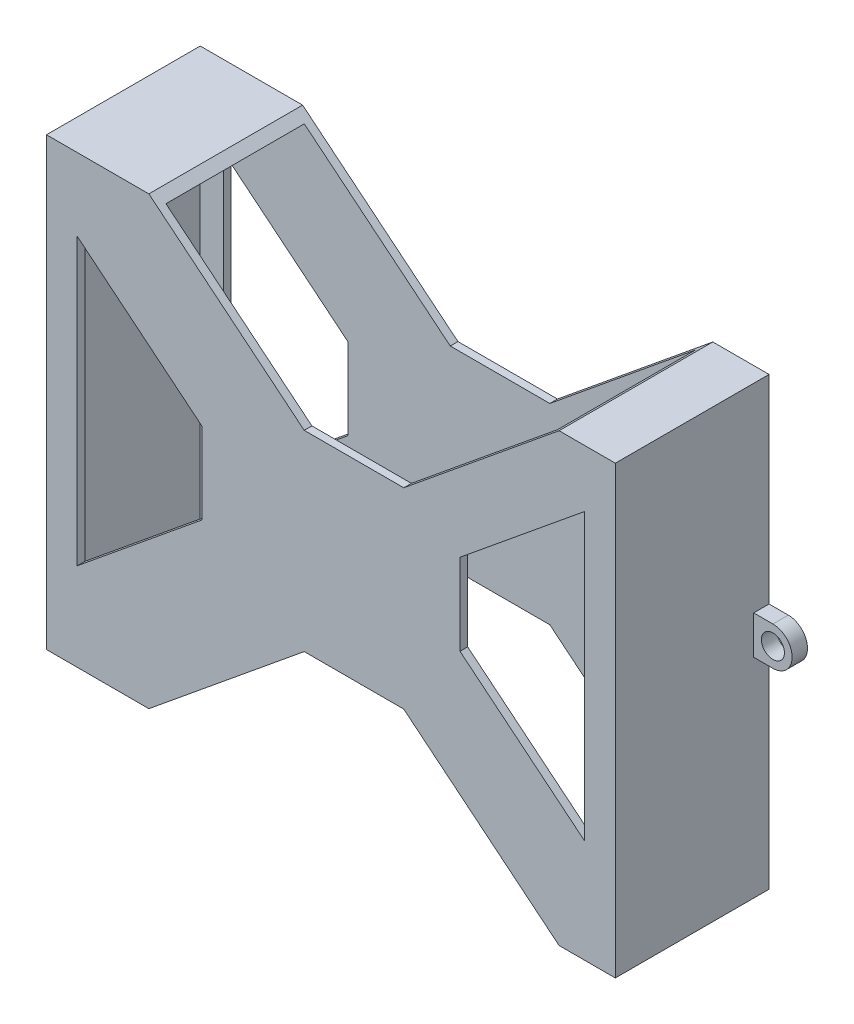
from build123d import *

# Parameters (mm, degrees)
BOSS_EXTRUDE2_DEPTH = 20
SHELL2_T            = -1
SKETCH2_R           = 1.5
BOSS_EXTRUDE4_DEPTH = 2


with BuildPart() as part:
    # Sketch1 → Boss-Extrude2 (new body)
    with BuildSketch(Plane.XY):
        Polygon((-3.474068414, 12.465208849), (-23.683257598, 29), (-37, 29), (-37, -29), (-23.683257598, -29), (-3.474068414, -12.465208849), (9.474068414, -12.465208849), (29.683257598, -29), (37, -29), (37, 29), (29.683257598, 29), (9.474068414, 12.465208849), align=None)
        Polygon((-33, 19.559028944), (-16.790810816, 6.296965066), (-16.790810816, -4.296965066), (-33, -17.559028944), align=None, mode=Mode.SUBTRACT)
        Polygon((16.790810816, 8.296965066), (33, 21.559028944), (33, -15.559028944), (16.790810816, -2.296965066), align=None, mode=Mode.SUBTRACT)
    extrude(amount=BOSS_EXTRUDE2_DEPTH)

    # Shell2
    shell2_openings = [part.faces().sort_by_distance(p)[0] for p in [
        (24.895405408, -8.927997005, 10),
        (33, 3, 10),
        (24.895405408, 14.927997005, 10),
        (16.790810816, 3, 10),
        (-16.790810816, 1, 10),
        (-24.895405408, 12.927997005, 10),
        (-33, 1, 10),
        (-24.895405408, -10.927997005, 10),
        (33.341628799, -29, 10),
        (19.578663006, -20.732604425, 10),
        (3, -12.465208849, 10),
        (-13.578663006, -20.732604425, 10),
        (-30.341628799, -29, 10),
        (-13.578663006, 20.732604425, 10),
        (3, 12.465208849, 10),
        (19.578663006, 20.732604425, 10),
    ]]
    offset(amount=SHELL2_T, openings=shell2_openings, kind=Kind.INTERSECTION)

    # Sketch2 → Boss-Extrude4 (add)
    with BuildSketch(Plane.XY):
        with BuildLine():
            Line((-39.5, -1.865744817), (-37, -1.865744817))
            Line((-37, -1.865744817), (-37, 3.134255183))
            Line((-37, 3.134255183), (-39.5, 3.134255183))
            ThreePointArc((-39.5, 3.134255183), (-42, 0.634255183), (-39.5, -1.865744817))
        make_face()
        with Locations((-39.5, 0.634255183)):
            Circle(SKETCH2_R, mode=Mode.SUBTRACT)
        with BuildLine():
            Line((39.5, 3.134255183), (37, 3.134255183))
            Line((37, 3.134255183), (37, -1.865744817))
            Line((37, -1.865744817), (39.5, -1.865744817))
            ThreePointArc((39.5, -1.865744817), (42, 0.634255183), (39.5, 3.134255183))
        make_face()
        with Locations((39.5, 0.634255183)):
            Circle(SKETCH2_R, mode=Mode.SUBTRACT)
    extrude(amount=BOSS_EXTRUDE4_DEPTH)


solid = part.part
